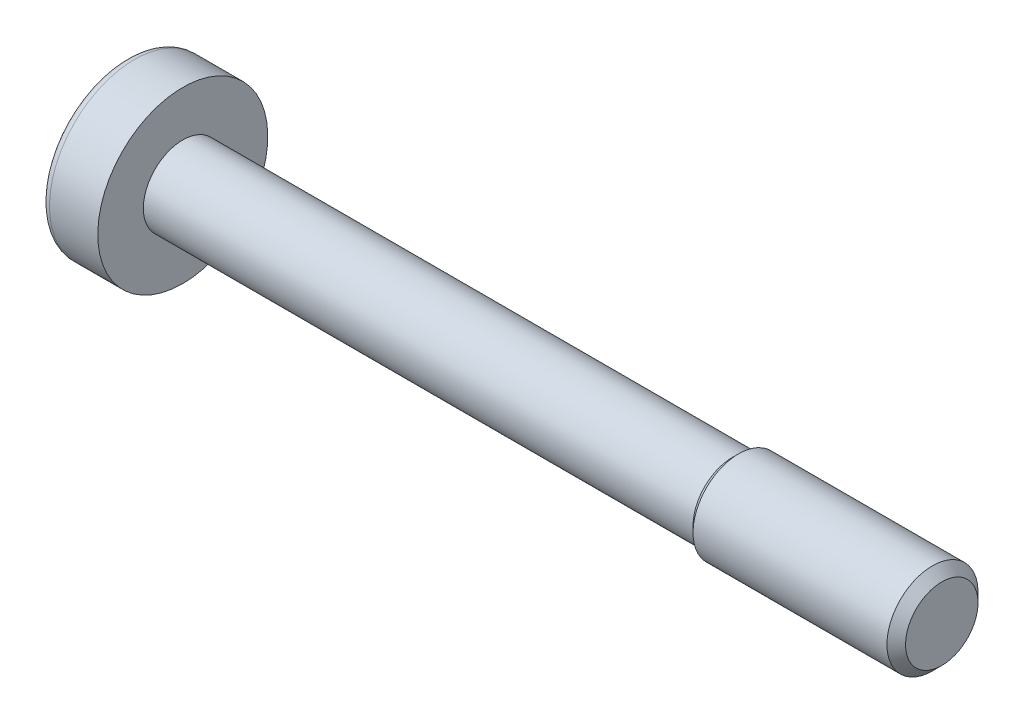
from build123d import *

# Parameters (mm, degrees)
CUT_EXTRUDE1_DEPTH = 2.16
SKETCH3_W          = 4.8
SKETCH3_H          = 0.88
CUT_EXTRUDE2_DEPTH = 2.16


with BuildPart() as part:
    # Sketch1 → Revolve1 (revolve)
    with BuildSketch(Plane.XY):
        with BuildLine():
            Line((-1.591709623, 0), (-2.4, 1.4))
            ThreePointArc((-2.4, 1.4), (-2.158282604, 2.05476512), (-1.827743487, 2.669491525))
            ThreePointArc((-1.827743487, 2.669491525), (-1.726160805, 2.765211773), (-1.590989852, 2.8))
            Line((-1.590989852, 2.8), (0, 2.8))
            Line((0, 2.8), (0, 1.3))
            Line((0, 1.3), (18.1065, 1.3))
            Line((18.1065, 1.3), (18.3065, 1.5))
            Line((18.3065, 1.5), (24.6935, 1.5))
            Line((24.6935, 1.5), (25, 1.1935))
            Line((25, 1.1935), (25, 0))
            Line((25, 0), (-1.591709623, 0))
        make_face()
    revolve(axis=Axis((25, 0, 0), (-1, 0, 0)))

    # Sketch2 → Cut-Extrude1 (cut)
    with BuildSketch(Plane(origin=(-2.4, 0, 0), x_dir=(0, 0, -1), z_dir=(1, 0, 0))):
        with BuildLine():
            ThreePointArc((-1.162126056, -0.356363636), (-1.212435563, -0.700000003), (-0.889682983, -0.828248867))
            ThreePointArc((-0.889682983, -0.828248867), (-0.504218428, -0.873331943), (-0.272443066, -1.184612505))
            ThreePointArc((-0.272443066, -1.184612505), (-6e-09, -1.4), (0.272443063, -1.184612516))
            ThreePointArc((0.272443063, -1.184612516), (0.504218427, -0.873331944), (0.88968299, -0.828248869))
            ThreePointArc((0.88968299, -0.828248869), (1.212435563, -0.700000005), (1.162126064, -0.356363644))
            ThreePointArc((1.162126064, -0.356363644), (1.008436863, -6e-09), (1.162126056, 0.356363636))
            ThreePointArc((1.162126056, 0.356363636), (1.212435565, 0.7), (0.88968299, 0.828248869))
            ThreePointArc((0.88968299, 0.828248869), (0.504218435, 0.873331939), (0.272443068, 1.184612496))
            ThreePointArc((0.272443068, 1.184612496), (7e-09, 1.4), (-0.272443065, 1.18461251))
            ThreePointArc((-0.272443065, 1.18461251), (-0.504218432, 0.873331941), (-0.889682997, 0.828248871))
            ThreePointArc((-0.889682997, 0.828248871), (-1.212435569, 0.699999994), (-1.162126051, 0.356363631))
            ThreePointArc((-1.162126051, 0.356363631), (-1.008436863, -4e-09), (-1.162126056, -0.356363636))
        make_face()
    extrude(amount=CUT_EXTRUDE1_DEPTH, mode=Mode.SUBTRACT)

    # Sketch3 → Cut-Extrude2 (cut)
    with BuildSketch(Plane(origin=(-2.4, 0, 0), x_dir=(0, 0, -1), z_dir=(1, 0, 0))):
        Rectangle(SKETCH3_W, SKETCH3_H)
    extrude(amount=CUT_EXTRUDE2_DEPTH, mode=Mode.SUBTRACT)


solid = part.part
